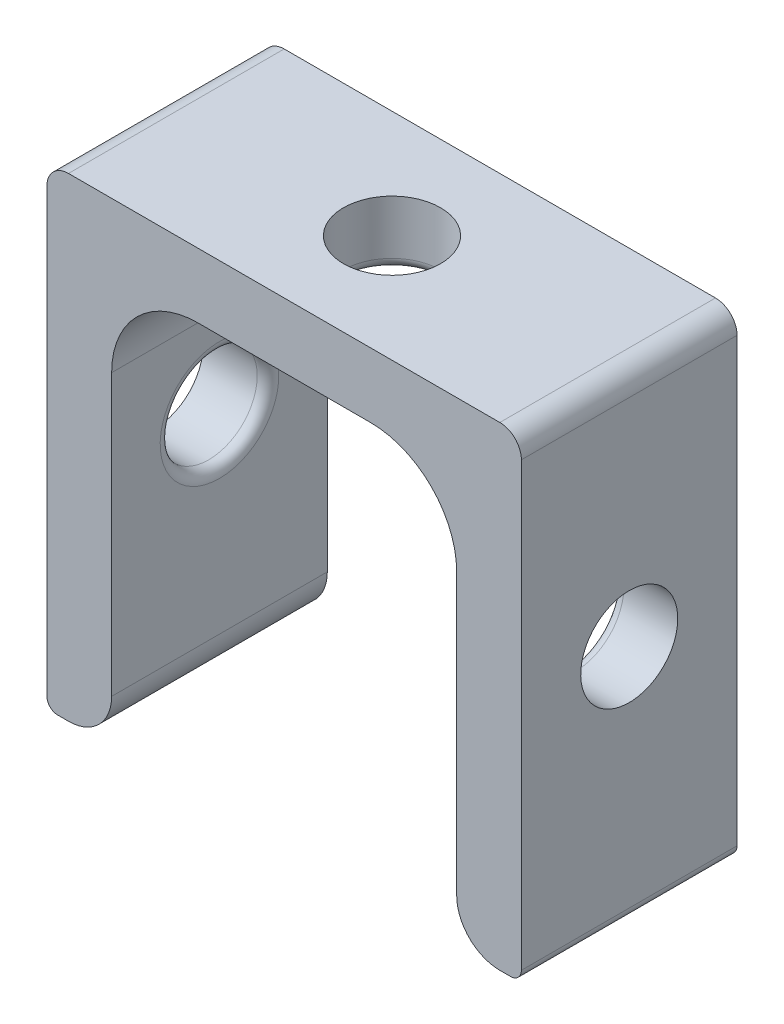
from build123d import *

# Parameters (mm, degrees)
EXTRUDE_1_DEPTH     = 10
SKETCH_4_R          = 2.25
CUT_EXTRUDE_1_DEPTH = 10
SKETCH_2_R          = 2.25
CUT_EXTRUDE_2_DEPTH = 27
FILLET_2_R          = 0.5
FILLET_3_R          = 1
FILLET_4_R          = 4


with BuildPart() as part:
    # 草图1 → 凸台-拉伸1 (new body)
    with BuildSketch(Plane.XY):
        with BuildLine():
            Line((-8, 0), (-8, -17))
            ThreePointArc((-8, -17), (-8.585786438, -18.414213562), (-10, -19))
            Line((-10, -19), (-10.5, -19))
            ThreePointArc((-10.5, -19), (-10.853553391, -18.853553391), (-11, -18.5))
            Line((-11, -18.5), (-11, 3))
            Line((-11, 3), (11, 3))
            Line((11, 3), (11, -18.5))
            ThreePointArc((11, -18.5), (10.853553391, -18.853553391), (10.5, -19))
            Line((10.5, -19), (10, -19))
            ThreePointArc((10, -19), (8.585786438, -18.414213562), (8, -17))
            Line((8, -17), (8, 0))
            Line((8, 0), (-8, 0))
        make_face()
    extrude(amount=EXTRUDE_1_DEPTH)

    # 草图4 → 切除-拉伸1 (cut)
    with BuildSketch(Plane(origin=(0, 0, 0), x_dir=(1, 0, 0), z_dir=(0, 1, 0))):
        with Locations((0, -5)):
            Circle(SKETCH_4_R)
    extrude(amount=CUT_EXTRUDE_1_DEPTH, mode=Mode.SUBTRACT)

    # 草图2 → 切除-拉伸2 (cut)
    with BuildSketch(Plane(origin=(11, 0, 0), x_dir=(0, 0, -1), z_dir=(1, 0, 0))):
        with Locations((-5, -8)):
            Circle(SKETCH_2_R)
    extrude(amount=-CUT_EXTRUDE_2_DEPTH, mode=Mode.SUBTRACT)

    # 圆角2
    fillet_2_edges = [part.edges().sort_by_distance(p)[0] for p in [
        (-2.25, 0, 5),
        (-8, -8, 7.25),
        (8, -8, 7.25),
    ]]
    fillet(fillet_2_edges, radius=FILLET_2_R)

    # 圆角3
    fillet_3_edges = [part.edges().sort_by_distance(p)[0] for p in [
        (-11, 3, 5),
        (11, 3, 5),
    ]]
    fillet(fillet_3_edges, radius=FILLET_3_R)

    # 圆角4
    fillet_4_edges = [part.edges().sort_by_distance(p)[0] for p in [
        (8, 0, 5),
        (-8, 0, 5),
    ]]
    fillet(fillet_4_edges, radius=FILLET_4_R)


solid = part.part
